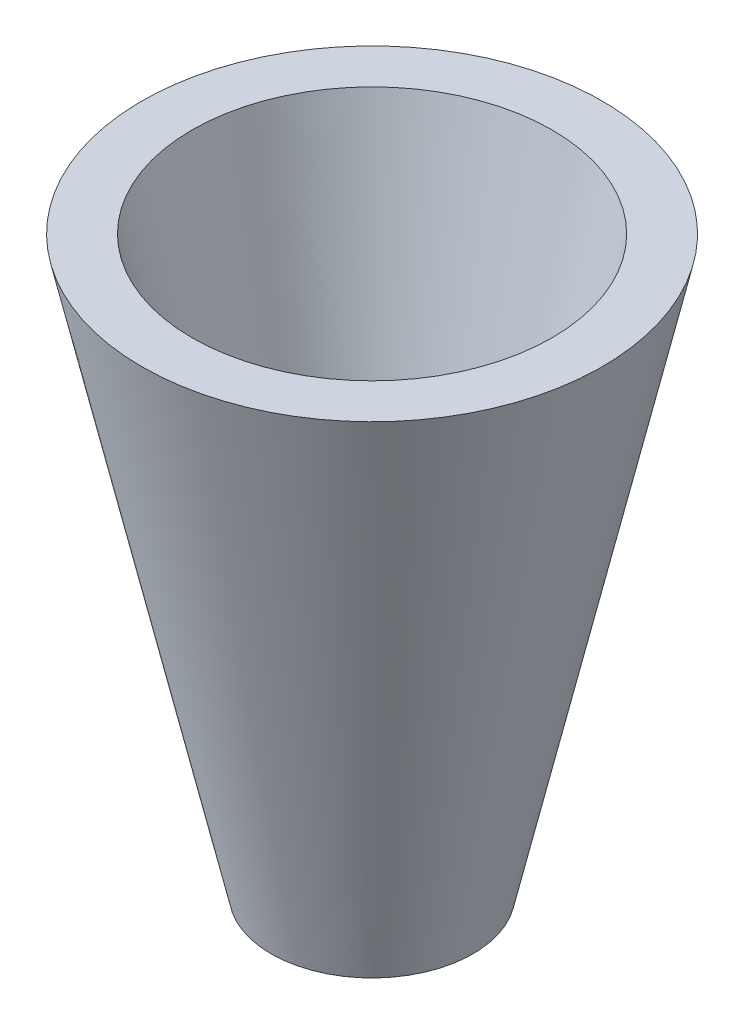
from build123d import *

# Parameters (mm, degrees)
VACIADO1_T = -10


with BuildPart() as part:
    # Croquis1 → Revolución1 (revolve)
    with BuildSketch(Plane.XY, mode=Mode.PRIVATE) as revoluci_n1_sk:
        Polygon((0, 55.467889177), (0, -61.711028218), (20.650382984, -61.711028218), (47.063663544, 55.467889177), align=None)
    revolve(revoluci_n1_sk.sketch.rotate(Axis((0, 55.467889177, 0), (0, -1, 0)), 90), axis=Axis((0, 55.467889177, 0), (0, -1, 0)))

    # Vaciado1
    vaciado1_openings = [part.faces().sort_by_distance(p)[0] for p in [
        (0, -61.711028218, 0),
        (0, 55.467889177, 0),
    ]]
    offset(amount=VACIADO1_T, openings=vaciado1_openings, kind=Kind.INTERSECTION)


solid = part.part
